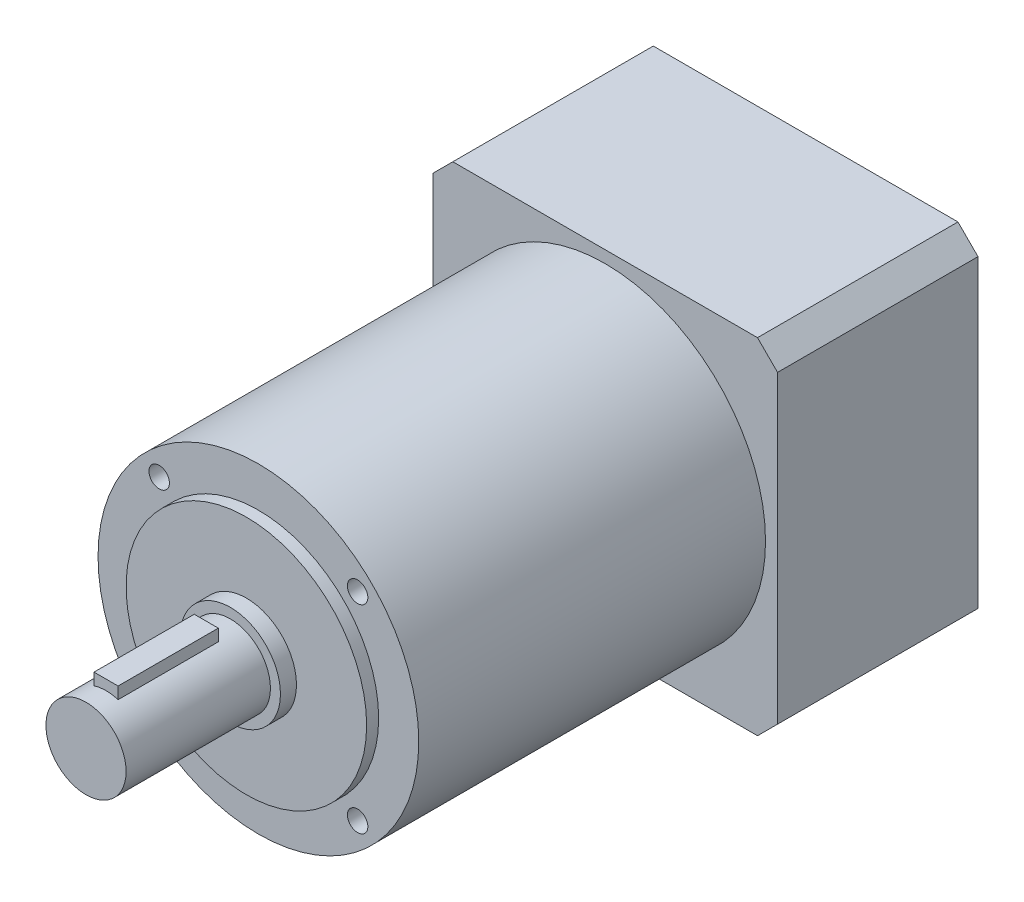
from build123d import *

# Parameters (mm, degrees)
SKETCH_1_W          = 86
SKETCH_1_H          = 86
EXTRUDE_1_DEPTH     = 50
SKETCH_2_R          = 40
EXTRUDE_2_DEPTH     = 86.5
SKETCH_3_R          = 30
EXTRUDE_3_DEPTH     = 3
SKETCH_4_R          = 12.5
EXTRUDE_4_DEPTH     = 4
SKETCH_5_R          = 10
EXTRUDE_5_DEPTH     = 36
SKETCH_7_W          = 6
SKETCH_7_H          = 25
EXTRUDE_6_DEPTH     = 12.5
SKETCH_8_R          = 36.5
CUT_EXTRUDE_1_DEPTH = 5
SKETCH_9_R          = 6.35
CUT_EXTRUDE_2_DEPTH = 30
SKETCH_10_R         = 2.1
CUT_EXTRUDE_3_DEPTH = 15
CHAMFER_1_SIZE      = 5
SKETCH_11_R         = 2.55
CUT_EXTRUDE_4_DEPTH = 15


with BuildPart() as part:
    # 草图1 → 凸台-拉伸1 (new body)
    with BuildSketch(Plane.XY):
        Rectangle(SKETCH_1_W, SKETCH_1_H)
    extrude(amount=EXTRUDE_1_DEPTH)

    # 草图2 → 凸台-拉伸2 (add)
    with BuildSketch(Plane.XY.offset(50)):
        Circle(SKETCH_2_R)
    extrude(amount=EXTRUDE_2_DEPTH)

    # 草图3 → 凸台-拉伸3 (add)
    with BuildSketch(Plane.XY.offset(136.5)):
        Circle(SKETCH_3_R)
    extrude(amount=EXTRUDE_3_DEPTH)

    # 草图4 → 凸台-拉伸4 (add)
    with BuildSketch(Plane.XY.offset(139.5)):
        Circle(SKETCH_4_R)
    extrude(amount=EXTRUDE_4_DEPTH)

    # 草图5 → 凸台-拉伸5 (add)
    with BuildSketch(Plane.XY.offset(143.5)):
        Circle(SKETCH_5_R)
    extrude(amount=EXTRUDE_5_DEPTH)

    # 草图7 → 凸台-拉伸6 (add)
    with BuildSketch(Plane(origin=(0, 0, 0), x_dir=(1, 0, 0), z_dir=(0, 1, 0))):
        with Locations((0, -162)):
            Rectangle(SKETCH_7_W, SKETCH_7_H)
    extrude(amount=EXTRUDE_6_DEPTH)

    # 草图8 → 切除-拉伸1 (cut)
    with BuildSketch(Plane(origin=(0, 0, 0), x_dir=(-1, 0, 0), z_dir=(0, 0, -1))):
        Circle(SKETCH_8_R)
    extrude(amount=-CUT_EXTRUDE_1_DEPTH, mode=Mode.SUBTRACT)

    # 草图9 → 切除-拉伸2 (cut)
    with BuildSketch(Plane(origin=(0, 0, 5), x_dir=(-1, 0, 0), z_dir=(0, 0, -1))):
        Circle(SKETCH_9_R)
    extrude(amount=-CUT_EXTRUDE_2_DEPTH, mode=Mode.SUBTRACT)

    # 草图10 → 切除-拉伸3 (cut)
    with BuildSketch(Plane(origin=(0, 0, 0), x_dir=(-1, 0, 0), z_dir=(0, 0, -1))):
        with Locations((-35, 35)):
            Circle(SKETCH_10_R)
        with Locations((35, 35)):
            Circle(SKETCH_10_R)
        with Locations((35, -35)):
            Circle(SKETCH_10_R)
        with Locations((-35, -35)):
            Circle(SKETCH_10_R)
    extrude(amount=-CUT_EXTRUDE_3_DEPTH, mode=Mode.SUBTRACT)

    # 倒角1
    chamfer_1_edges = [part.edges().sort_by_distance(p)[0] for p in [
        (-43, 43, 25),
        (43, 43, 25),
        (43, -43, 25),
        (-43, -43, 25),
    ]]
    chamfer(chamfer_1_edges, length=CHAMFER_1_SIZE)

    # 草图11 → 切除-拉伸4 (cut)
    with BuildSketch(Plane.XY.offset(136.5)):
        with Locations((-24.748737342, 24.748737342)):
            Circle(SKETCH_11_R)
        with Locations((24.748737342, 24.748737342)):
            Circle(SKETCH_11_R)
        with Locations((24.748737342, -24.748737342)):
            Circle(SKETCH_11_R)
        with Locations((-24.748737342, -24.748737342)):
            Circle(SKETCH_11_R)
    extrude(amount=-CUT_EXTRUDE_4_DEPTH, mode=Mode.SUBTRACT)


solid = part.part
